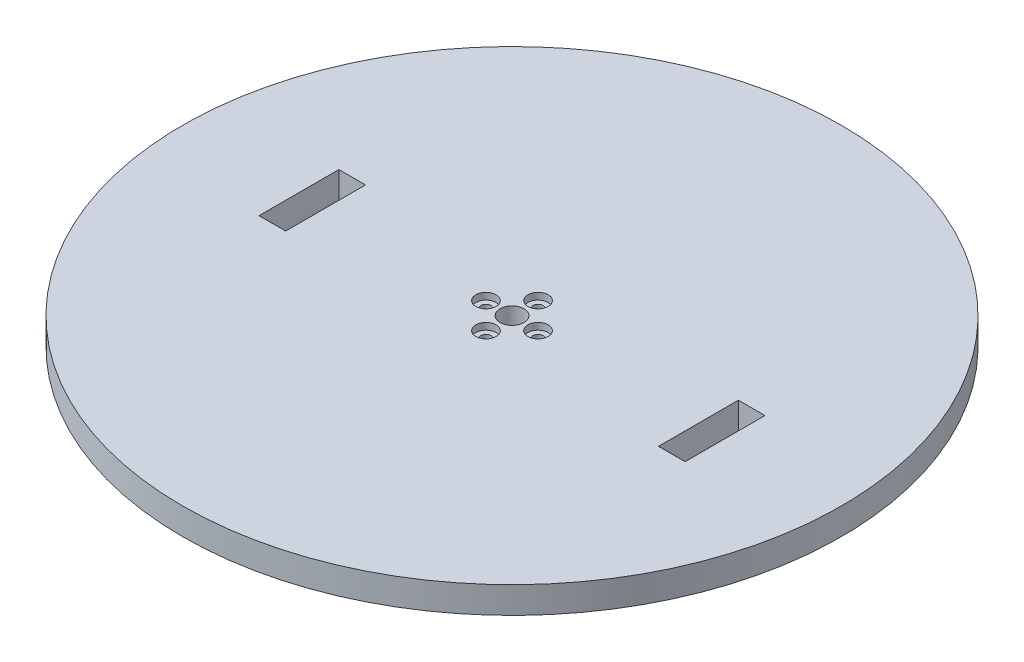
from build123d import *

# Parameters (mm, degrees)
SKETCH1_R           = 123.75
BOSS_EXTRUDE1_DEPTH = 10
SKETCH2_R           = 1.905
CUT_EXTRUDE2_DEPTH  = 11
CIRPATTERN1_COUNT   = 4
SKETCH3_R           = 4.5
CUT_EXTRUDE3_DEPTH  = 11
SKETCH4_R           = 3.81
CUT_EXTRUDE4_DEPTH  = 2.54
CIRPATTERN2_COUNT   = 4
SKETCH5_W           = 10
SKETCH5_H           = 30
CUT_EXTRUDE5_DEPTH  = 11


with BuildPart() as part:
    # Sketch1 → Boss-Extrude1 (new body)
    with BuildSketch(Plane(origin=(0, 0, 0), x_dir=(1, 0, 0), z_dir=(0, 1, 0))):
        Circle(SKETCH1_R)
    extrude(amount=BOSS_EXTRUDE1_DEPTH)

    # Sketch2 → Cut-Extrude2 (cut, through all)
    with BuildSketch(Plane(origin=(0, 10, 0), x_dir=(1, 0, 0), z_dir=(0, 1, 0))):
        with Locations((0, 9.779)):
            Circle(SKETCH2_R)
    cut_extrude2 = extrude(amount=-CUT_EXTRUDE2_DEPTH, mode=Mode.SUBTRACT)

    # CirPattern1: Cut-Extrude2 ×4 about axis
    cirpattern1_axis = Axis((0, 0, 0), (0, 1, 0))
    for i in range(1, CIRPATTERN1_COUNT):
        add(cut_extrude2.rotate(cirpattern1_axis, i * 360 / CIRPATTERN1_COUNT), mode=Mode.SUBTRACT)

    # Sketch3 → Cut-Extrude3 (cut, through all)
    with BuildSketch(Plane(origin=(0, 10, 0), x_dir=(1, 0, 0), z_dir=(0, 1, 0))):
        Circle(SKETCH3_R)
    extrude(amount=-CUT_EXTRUDE3_DEPTH, mode=Mode.SUBTRACT)

    # Sketch4 → Cut-Extrude4 (cut)
    with BuildSketch(Plane(origin=(0, 10, 0), x_dir=(1, 0, 0), z_dir=(0, 1, 0))):
        with Locations((0, 9.779)):
            Circle(SKETCH4_R)
    cut_extrude4 = extrude(amount=-CUT_EXTRUDE4_DEPTH, mode=Mode.SUBTRACT)

    # CirPattern2: Cut-Extrude4 ×4 about axis
    cirpattern2_axis = Axis((0, 0, 0), (0, 1, 0))
    for i in range(1, CIRPATTERN2_COUNT):
        add(cut_extrude4.rotate(cirpattern2_axis, i * 360 / CIRPATTERN2_COUNT), mode=Mode.SUBTRACT)

    # Sketch5 → Cut-Extrude5 (cut, through all)
    with BuildSketch(Plane(origin=(0, 10, 0), x_dir=(1, 0, 0), z_dir=(0, 1, 0))):
        with Locations((75, 0)):
            Rectangle(SKETCH5_W, SKETCH5_H)
        with Locations((-75, 0)):
            Rectangle(SKETCH5_W, SKETCH5_H)
    extrude(amount=-CUT_EXTRUDE5_DEPTH, mode=Mode.SUBTRACT)


solid = part.part
